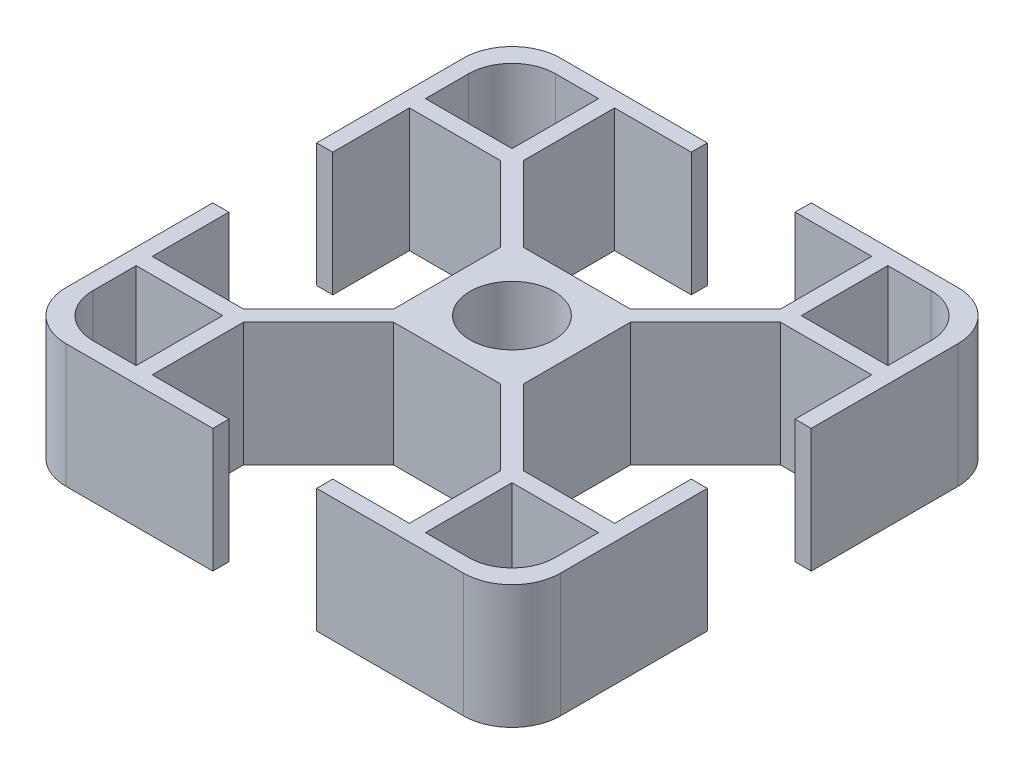
from build123d import *

# Parameters (mm, degrees)
SKETCH_1_W      = 6.2
SKETCH_1_H      = 1.3
SKETCH_1_W_2    = 1.3
SKETCH_1_H_2    = 6.2
SKETCH_1_W_3    = 10.5
SKETCH_1_H_3    = 10.5
SKETCH_1_R      = 3.4
EXTRUDE_2_DEPTH = 10


with BuildPart() as part:
    # 草图1 → 凸台-拉伸2 (new body)
    with BuildSketch(Plane(origin=(0, 0, 0), x_dir=(1, 0, 0), z_dir=(0, 1, 0))):
        with Locations((-7.3, -19.35)):
            Rectangle(SKETCH_1_W, SKETCH_1_H)
        with BuildLine():
            Line((-18.7, -10.4), (-20, -10.4))
            Line((-20, -10.4), (-20, -16.079155302))
            ThreePointArc((-20, -16.079155302), (-18.851611176, -18.851611176), (-16.079155302, -20))
            Line((-16.079155302, -20), (-10.4, -20))
            Line((-10.4, -20), (-10.4, -18.7))
            Line((-10.4, -18.7), (-10.4, -11.319238816))
            Line((-10.4, -11.319238816), (-10.4, -10.4))
            Line((-10.4, -10.4), (-11.319238816, -10.4))
            Line((-11.319238816, -10.4), (-18.7, -10.4))
        make_face()
        Polygon((-18.7, -15.2), (-18.7, -11.7), (-15.2, -11.7), (-11.7, -11.7), (-11.7, -15.2), (-11.7, -18.7), (-15.2, -18.7), (-18.7, -18.7), align=None, mode=Mode.SUBTRACT)
        with Locations((-19.35, -7.3)):
            Rectangle(SKETCH_1_W_2, SKETCH_1_H_2)
        with BuildLine():
            ThreePointArc((-15.2, -18.7), (-17.674873734, -17.674873734), (-18.7, -15.2))
            Line((-18.7, -15.2), (-18.7, -18.7))
            Line((-18.7, -18.7), (-15.2, -18.7))
        make_face()
        Polygon((-5.25, -5.25), (-5.25, -4.330761184), (-11.319238816, -10.4), (-10.4, -10.4), (-10.4, -11.319238816), (-4.330761184, -5.25), align=None)
        Rectangle(SKETCH_1_W_3, SKETCH_1_H_3)
        with Locations(Location((0, 0, 0), (0, 0, 270))):
            Circle(SKETCH_1_R, mode=Mode.SUBTRACT)
        Polygon((11.319238816, -10.4), (5.25, -4.330761184), (5.25, -5.25), (4.330761184, -5.25), (10.4, -11.319238816), (10.4, -10.4), align=None)
        Polygon((10.4, 11.319238816), (4.330761184, 5.25), (5.25, 5.25), (5.25, 4.330761184), (11.319238816, 10.4), (10.4, 10.4), align=None)
        Polygon((-4.330761184, 5.25), (-10.4, 11.319238816), (-10.4, 10.4), (-11.319238816, 10.4), (-5.25, 4.330761184), (-5.25, 5.25), align=None)
        with BuildLine():
            Line((18.7, -10.4), (11.319238816, -10.4))
            Line((11.319238816, -10.4), (10.4, -10.4))
            Line((10.4, -10.4), (10.4, -11.319238816))
            Line((10.4, -11.319238816), (10.4, -18.7))
            Line((10.4, -18.7), (10.4, -20))
            Line((10.4, -20), (16.079155302, -20))
            ThreePointArc((16.079155302, -20), (18.851611176, -18.851611176), (20, -16.079155302))
            Line((20, -16.079155302), (20, -10.4))
            Line((20, -10.4), (18.7, -10.4))
        make_face()
        Polygon((15.2, -11.7), (18.7, -11.7), (18.7, -15.2), (18.7, -18.7), (15.2, -18.7), (11.7, -18.7), (11.7, -15.2), (11.7, -11.7), align=None, mode=Mode.SUBTRACT)
        with BuildLine():
            Line((18.7, -18.7), (18.7, -15.2))
            ThreePointArc((18.7, -15.2), (17.674873734, -17.674873734), (15.2, -18.7))
            Line((15.2, -18.7), (18.7, -18.7))
        make_face()
        with BuildLine():
            Line((16.079155302, 20), (10.4, 20))
            Line((10.4, 20), (10.4, 18.7))
            Line((10.4, 18.7), (10.4, 11.319238816))
            Line((10.4, 11.319238816), (10.4, 10.4))
            Line((10.4, 10.4), (11.319238816, 10.4))
            Line((11.319238816, 10.4), (18.7, 10.4))
            Line((18.7, 10.4), (20, 10.4))
            Line((20, 10.4), (20, 16.079155302))
            ThreePointArc((20, 16.079155302), (18.851611176, 18.851611176), (16.079155302, 20))
        make_face()
        Polygon((15.2, 18.7), (18.7, 18.7), (18.7, 15.2), (18.7, 11.7), (15.2, 11.7), (11.7, 11.7), (11.7, 15.2), (11.7, 18.7), align=None, mode=Mode.SUBTRACT)
        with BuildLine():
            Line((18.7, 15.2), (18.7, 18.7))
            Line((18.7, 18.7), (15.2, 18.7))
            ThreePointArc((15.2, 18.7), (17.674873734, 17.674873734), (18.7, 15.2))
        make_face()
        with BuildLine():
            Line((-10.4, 20), (-16.079155302, 20))
            ThreePointArc((-16.079155302, 20), (-18.851611176, 18.851611176), (-20, 16.079155302))
            Line((-20, 16.079155302), (-20, 10.4))
            Line((-20, 10.4), (-18.7, 10.4))
            Line((-18.7, 10.4), (-11.319238816, 10.4))
            Line((-11.319238816, 10.4), (-10.4, 10.4))
            Line((-10.4, 10.4), (-10.4, 11.319238816))
            Line((-10.4, 11.319238816), (-10.4, 18.7))
            Line((-10.4, 18.7), (-10.4, 20))
        make_face()
        Polygon((-15.2, 11.7), (-18.7, 11.7), (-18.7, 15.2), (-18.7, 18.7), (-15.2, 18.7), (-11.7, 18.7), (-11.7, 15.2), (-11.7, 11.7), align=None, mode=Mode.SUBTRACT)
        with BuildLine():
            Line((-18.7, 18.7), (-18.7, 15.2))
            ThreePointArc((-18.7, 15.2), (-17.674873734, 17.674873734), (-15.2, 18.7))
            Line((-15.2, 18.7), (-18.7, 18.7))
        make_face()
        with Locations((-7.3, 19.35)):
            Rectangle(SKETCH_1_W, SKETCH_1_H)
        with Locations((7.3, 19.35)):
            Rectangle(SKETCH_1_W, SKETCH_1_H)
        with Locations((19.35, 7.3)):
            Rectangle(SKETCH_1_W_2, SKETCH_1_H_2)
        with Locations((-19.35, 7.3)):
            Rectangle(SKETCH_1_W_2, SKETCH_1_H_2)
        with Locations((19.35, -7.3)):
            Rectangle(SKETCH_1_W_2, SKETCH_1_H_2)
        with Locations((7.3, -19.35)):
            Rectangle(SKETCH_1_W, SKETCH_1_H)
    extrude(amount=EXTRUDE_2_DEPTH)


solid = part.part
